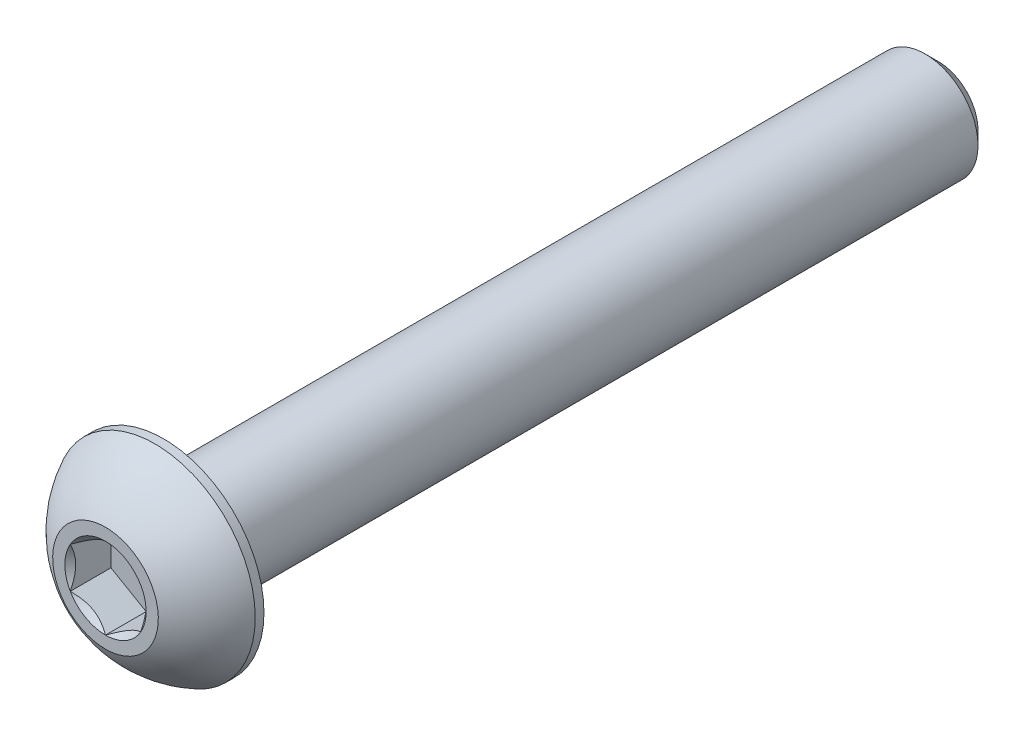
from build123d import *

# Parameters (mm, degrees)
SKETCH1_W          = 22
SKETCH1_H          = 1.5
CHAMFER1_SIZE      = 0.375
CUT_EXTRUDE2_DEPTH = 1.155


with BuildPart() as part:
    # Sketch1 → Revolve1 (revolve)
    with BuildSketch(Plane(origin=(0, 0, 0), x_dir=(0, 0, -1), z_dir=(1, 0, 0))):
        with Locations((12.65, 0.75)):
            Rectangle(SKETCH1_W, SKETCH1_H)
    revolve(axis=Axis((0, 0, -23.65), (0, 0, 1)))

    # Chamfer1
    chamfer1_edges = [part.edges().sort_by_distance(p)[0] for p in [
        (0, -1.5, -23.65),
    ]]
    chamfer(chamfer1_edges, length=CHAMFER1_SIZE)

    # Sketch7 → Revolve2 (revolve)
    with BuildSketch(Plane(origin=(0, 0, 0), x_dir=(0, 0, -1), z_dir=(1, 0, 0))):
        with BuildLine():
            Line((1.4025, 2.85), (1.65, 2.85))
            Line((1.65, 2.85), (1.65, 0))
            Line((1.65, 0), (0, 0))
            Line((0, 0), (0, 1.5))
            ThreePointArc((0, 1.5), (0.59512511, 2.285251969), (1.4025, 2.85))
        make_face()
    revolve(axis=Axis((0, 0, 0), (0, 0, -1)))

    # Sketch5 → Cut-Extrude2 (cut)
    with BuildSketch(Plane.XY):
        Polygon((1, -0.577350269), (1, 0.577350269), (0, 1.154700538), (-1, 0.577350269), (-1, -0.577350269), (0, -1.154700538), align=None)
    extrude(amount=-CUT_EXTRUDE2_DEPTH, mode=Mode.SUBTRACT)

    # Cut-Extrude3 cone 1 section (through the dimple's axis) → Cut-Extrude3 (revolve, cut)
    with BuildSketch(Plane(origin=(0, 0, 0), x_dir=(0, -1, 0), z_dir=(1, 0, 0))):
        Polygon((0, 0), (1.154700538, 0), (0, 1.154700538), align=None)
    revolve(axis=Axis((0, 0, 0), (0, 0, -1)), mode=Mode.SUBTRACT)


solid = part.part
